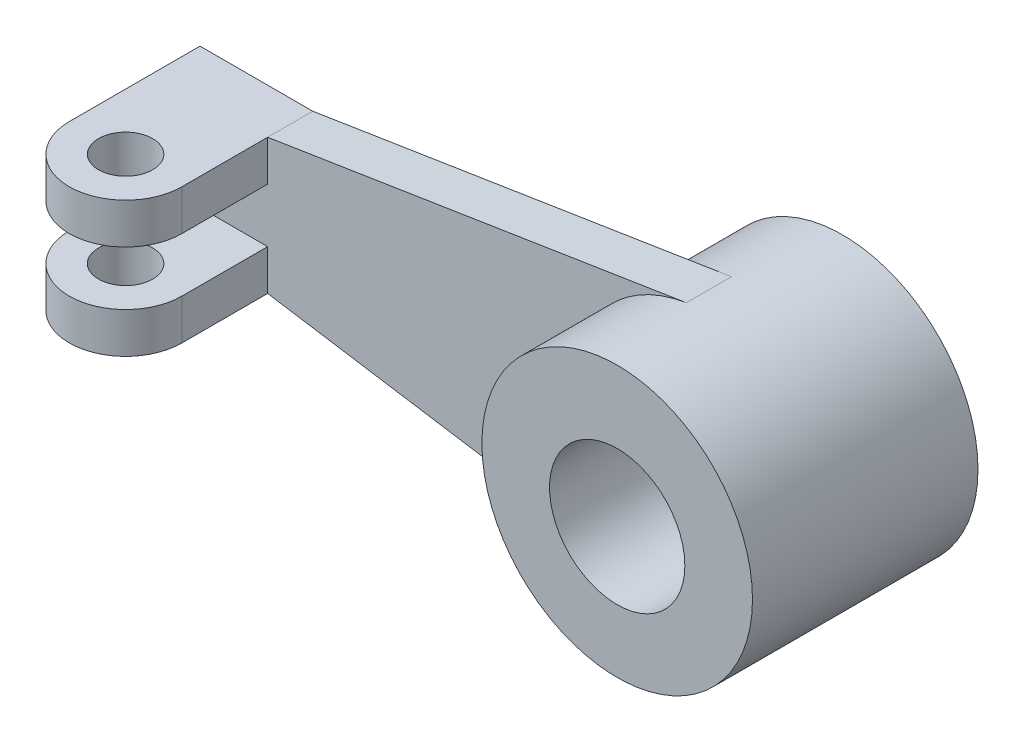
from build123d import *

# Parameters (mm, degrees)
SKETCH1_R           = 30
SKETCH1_R_2         = 15
BOSS_EXTRUDE1_DEPTH = 25
BOSS_EXTRUDE3_DEPTH = 5
SKETCH4_R           = 6
BOSS_EXTRUDE4_DEPTH = 9


with BuildPart() as part:
    # Sketch1 → Boss-Extrude1 (new body, symmetric)
    with BuildSketch(Plane.XY):
        Circle(SKETCH1_R)
        with Locations((0, -1.007153664)):
            Circle(SKETCH1_R_2, mode=Mode.SUBTRACT)
    extrude(amount=BOSS_EXTRUDE1_DEPTH, both=True)

    # Sketch2 → Boss-Extrude3 (add, symmetric)
    with BuildSketch(Plane.XY):
        with BuildLine():
            Line((-122.5, 15), (-122.5, -15))
            Line((-122.5, -15), (-97.5, -15))
            Line((-97.5, -15), (-4.671688756, -29.634023084))
            ThreePointArc((-4.671688756, -29.634023084), (-30, 0), (-4.671688756, 29.634023084))
            Line((-4.671688756, 29.634023084), (-97.5, 15))
            Line((-97.5, 15), (-122.5, 15))
        make_face()
    extrude(amount=BOSS_EXTRUDE3_DEPTH, both=True)

    # Sketch4 → Boss-Extrude4 (add)
    with BuildSketch(Plane(origin=(0, -15, 0), x_dir=(-1, 0, 0), z_dir=(0, -1, 0))):
        with BuildLine():
            Line((122.5, -24), (122.5, -5))
            Line((122.5, -5), (97.5, -5))
            Line((97.5, -5), (97.5, -24))
            ThreePointArc((97.5, -24), (110, -36.5), (122.5, -24))
        make_face()
        with Locations(Location((110, -24, 0), (0, 0, 180))):  # turned: the seam where the file's is
            Circle(SKETCH4_R, mode=Mode.SUBTRACT)
    boss_extrude4 = extrude(amount=-BOSS_EXTRUDE4_DEPTH)

    # Mirror1: Boss-Extrude4 across plane
    add(boss_extrude4.mirror(Plane.ZX))


solid = part.part
